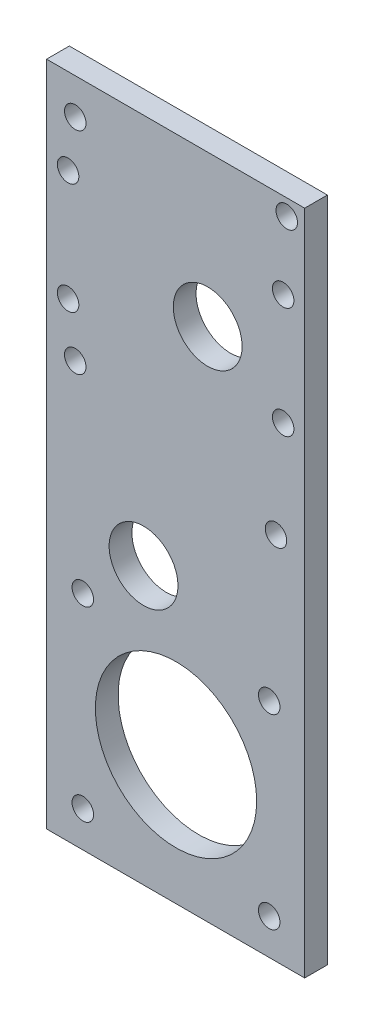
from build123d import *

# Parameters (mm, degrees)
SKETCH2_W           = 36
SKETCH2_H           = 93
SKETCH2_R           = 1.5
SKETCH2_R_2         = 11.25
SKETCH2_R_3         = 4.8
BOSS_EXTRUDE1_DEPTH = 3.175
SKETCH3_R           = 1.5
CUT_EXTRUDE1_DEPTH  = 16


with BuildPart() as part:
    # Sketch2 → Boss-Extrude1 (new body)
    with BuildSketch(Plane.XY):
        with Locations((0, 7.942942894)):
            Rectangle(SKETCH2_W, SKETCH2_H)
        with Locations((13.053786058, -33.557057106)):
            Circle(SKETCH2_R, mode=Mode.SUBTRACT)
        with Locations((13.053786058, -7.557057106)):
            Circle(SKETCH2_R, mode=Mode.SUBTRACT)
        with Locations((-12.946213942, -33.557057106)):
            Circle(SKETCH2_R, mode=Mode.SUBTRACT)
        with Locations((-12.946213942, -7.557057106)):
            Circle(SKETCH2_R, mode=Mode.SUBTRACT)
        with Locations((0.053786058, -20.557057106)):
            Circle(SKETCH2_R_2, mode=Mode.SUBTRACT)
        with Locations((-4.475, 0)):
            Circle(SKETCH2_R_3, mode=Mode.SUBTRACT)
        with Locations((4.475, 33.370645783)):
            Circle(SKETCH2_R_3, mode=Mode.SUBTRACT)
        with Locations((14, 13)):
            Circle(SKETCH2_R, mode=Mode.SUBTRACT)
        with Locations((-14, 20)):
            Circle(SKETCH2_R, mode=Mode.SUBTRACT)
        with Locations((-14, 49.442942894)):
            Circle(SKETCH2_R, mode=Mode.SUBTRACT)
        with Locations((15.5, 52.187088466)):
            Circle(SKETCH2_R, mode=Mode.SUBTRACT)
    extrude(amount=BOSS_EXTRUDE1_DEPTH)

    # Sketch3 → Cut-Extrude1 (cut)
    with BuildSketch(Plane.XY.offset(3.175)):
        with Locations((-15, 42.5)):
            Circle(SKETCH3_R)
        with Locations((15, 42.5)):
            Circle(SKETCH3_R)
        with Locations((-15, 27)):
            Circle(SKETCH3_R)
        with Locations((15, 27)):
            Circle(SKETCH3_R)
    extrude(amount=-CUT_EXTRUDE1_DEPTH, mode=Mode.SUBTRACT)


solid = part.part
